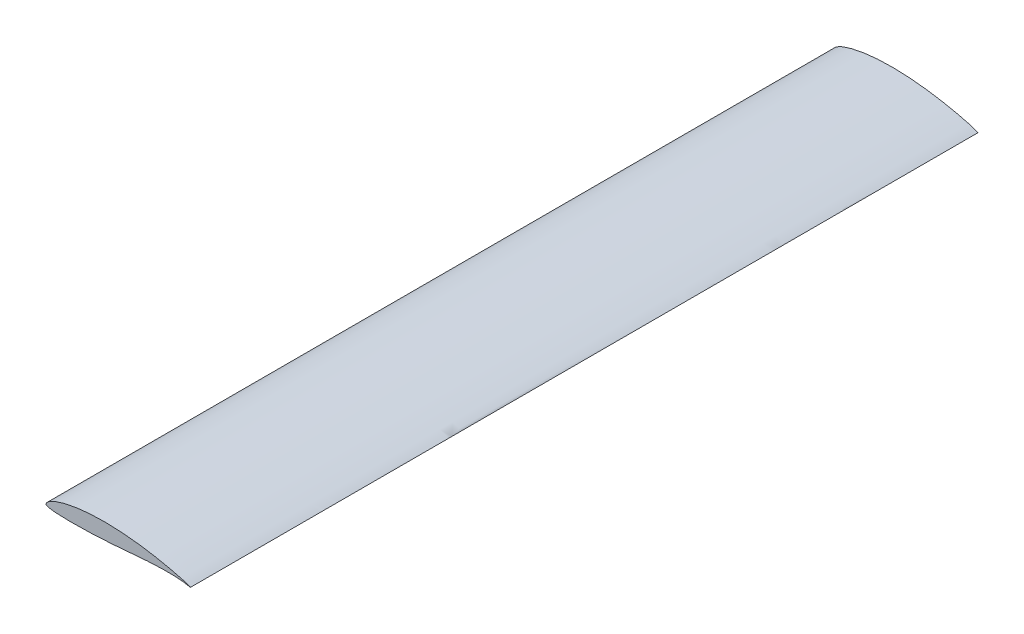
from build123d import *

# Parameters (mm, degrees)
BOSS_EXTRUDE1_DEPTH = 1200


with BuildPart() as part:
    # Sketch1 → Boss-Extrude1 (new body)
    with BuildSketch(Plane.XY):
        with BuildLine():
            add(Edge.make_bspline(
                [(220, 0), (219.998135988, 0.019122613), (218.563925507, 0.543091868), (217.202877024, 1.195161949), (214.031942043, 2.457002664), (210.151500294, 3.725675551), (205.115001186, 5.159823925), (199.149888904, 6.712098532), (192.261767895, 8.370441408), (184.567092504, 10.095016841), (176.157547087, 11.84810975), (167.144050476, 13.589110484), (157.63138878, 15.261293748), (147.724085726, 16.811623945), (137.514484093, 18.179875485), (127.090971309, 19.317567771), (116.547260473, 20.21136432), (105.97618671, 20.843121168), (95.47464801, 21.185419039), (85.134830962, 21.232115385), (75.048009668, 20.984046136), (65.298833438, 20.430858305), (55.969659866, 19.586579031), (47.13776071, 18.471781021), (38.878354138, 17.121295206), (31.26702647, 15.552547463), (24.3698269, 13.815802625), (18.251015376, 11.932474073), (12.961995314, 9.953692336), (8.542784229, 7.920133493), (5.033123906, 5.88366432), (2.412800466, 3.863201159), (0.795770018, 1.976834958), (0.019314765, 0.644286641), (-0.013203266, -0.382736012), (0.652064303, -1.496057825), (2.845448307, -2.142586284), (5.954643569, -2.984403065), (10.312781637, -3.584466057), (15.741724056, -4.100872863), (22.236709295, -4.45687261), (29.709916283, -4.675957215), (38.085618784, -4.7585228), (47.26778145, -4.701611609), (57.153841207, -4.511490736), (67.63545071, -4.188810022), (78.599360208, -3.720368449), (89.934357058, -3.118304305), (101.539496695, -2.357258092), (113.340300932, -1.414800103), (125.26538602, -0.326588307), (137.222746021, 0.727046983), (149.057254793, 1.66339154), (160.582212642, 2.41121225), (171.603566779, 2.916252399), (181.921027751, 3.156899073), (191.351550468, 3.111460628), (199.668522118, 2.813794382), (206.782546863, 2.251223284), (212.210903629, 1.582557474), (216.562666492, 0.757675809), (218.315737755, 0.434906763), (220.00196895, -0.020199156), (220, 0)],
                knots=[0, 0, 0, 0, 0.001693524, 0.006395447, 0.013461651, 0.022753575, 0.034367307, 0.048191023, 0.064031392, 0.081680617, 0.100894124, 0.121431794, 0.143025453, 0.165434011, 0.188439039, 0.211855124, 0.235496289, 0.259143745, 0.282614908, 0.305701545, 0.328231584, 0.350030434, 0.370943883, 0.390816529, 0.409505873, 0.42685655, 0.442733385, 0.457018388, 0.46961507, 0.480449695, 0.48947186, 0.496730301, 0.502329147, 0.50625566, 0.506441945, 0.509181516, 0.513913846, 0.521178419, 0.530944157, 0.543144509, 0.557669674, 0.574383526, 0.593109554, 0.613638212, 0.635743557, 0.659184095, 0.683713689, 0.709075754, 0.735036066, 0.761429739, 0.788183766, 0.81505683, 0.841644764, 0.86751356, 0.892232409, 0.915363656, 0.936485325, 0.955199832, 0.971104187, 0.983751026, 0.992812818, 0.998211136, 1, 1, 1, 1], degree=3))
        make_face()
    extrude(amount=BOSS_EXTRUDE1_DEPTH)


solid = part.part
